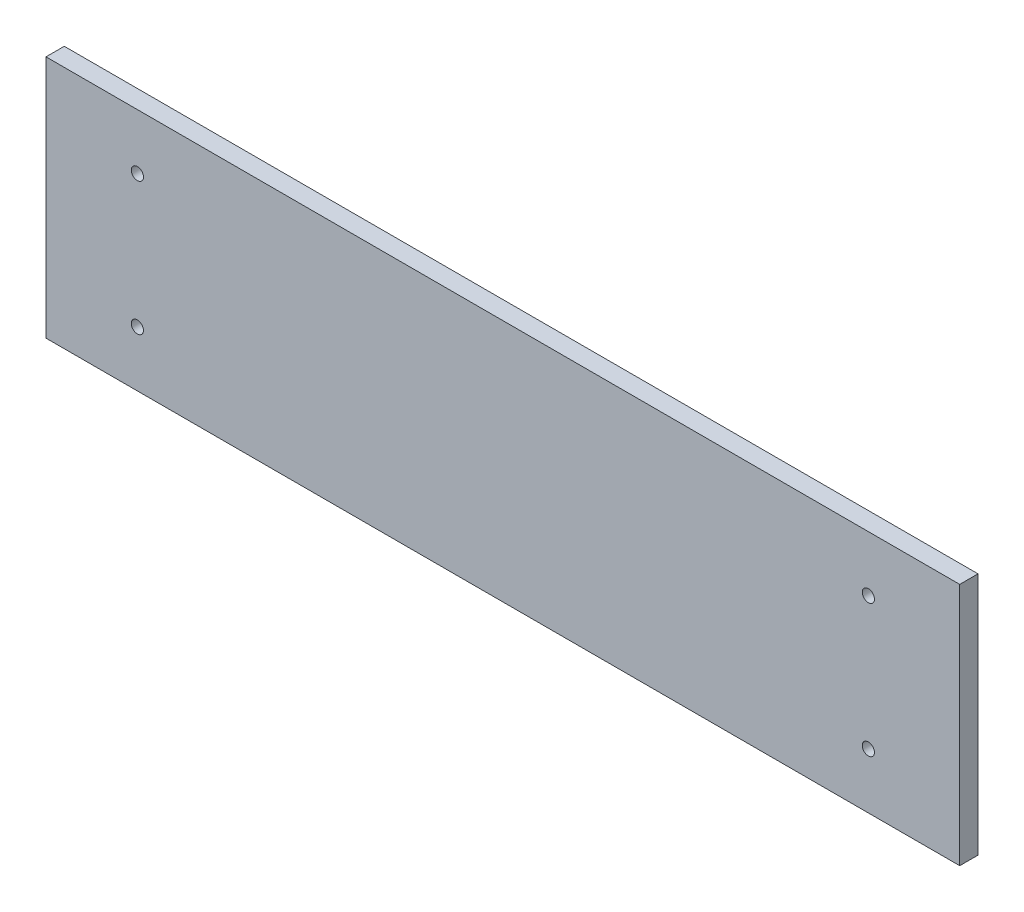
from build123d import *

# Parameters (mm, degrees)
SKETCH1_W           = 150
SKETCH1_H           = 40
BOSS_EXTRUDE1_DEPTH = 3
SKETCH2_R           = 1
CUT_EXTRUDE1_DEPTH  = 10


with BuildPart() as part:
    # Sketch1 → Boss-Extrude1 (new body)
    with BuildSketch(Plane.XY):
        with Locations((-2.486910995, 5.785340314)):
            Rectangle(SKETCH1_W, SKETCH1_H)
    extrude(amount=BOSS_EXTRUDE1_DEPTH)

    # Sketch2 → Cut-Extrude1 (cut)
    with BuildSketch(Plane.XY.offset(3)):
        with Locations((-62.486910995, 16.685340314)):
            Circle(SKETCH2_R)
        with Locations((57.513089005, 16.685340314)):
            Circle(SKETCH2_R)
        with Locations((57.513089005, -5.114659686)):
            Circle(SKETCH2_R)
        with Locations((-62.486910995, -5.114659686)):
            Circle(SKETCH2_R)
    extrude(amount=-CUT_EXTRUDE1_DEPTH, mode=Mode.SUBTRACT)


solid = part.part
